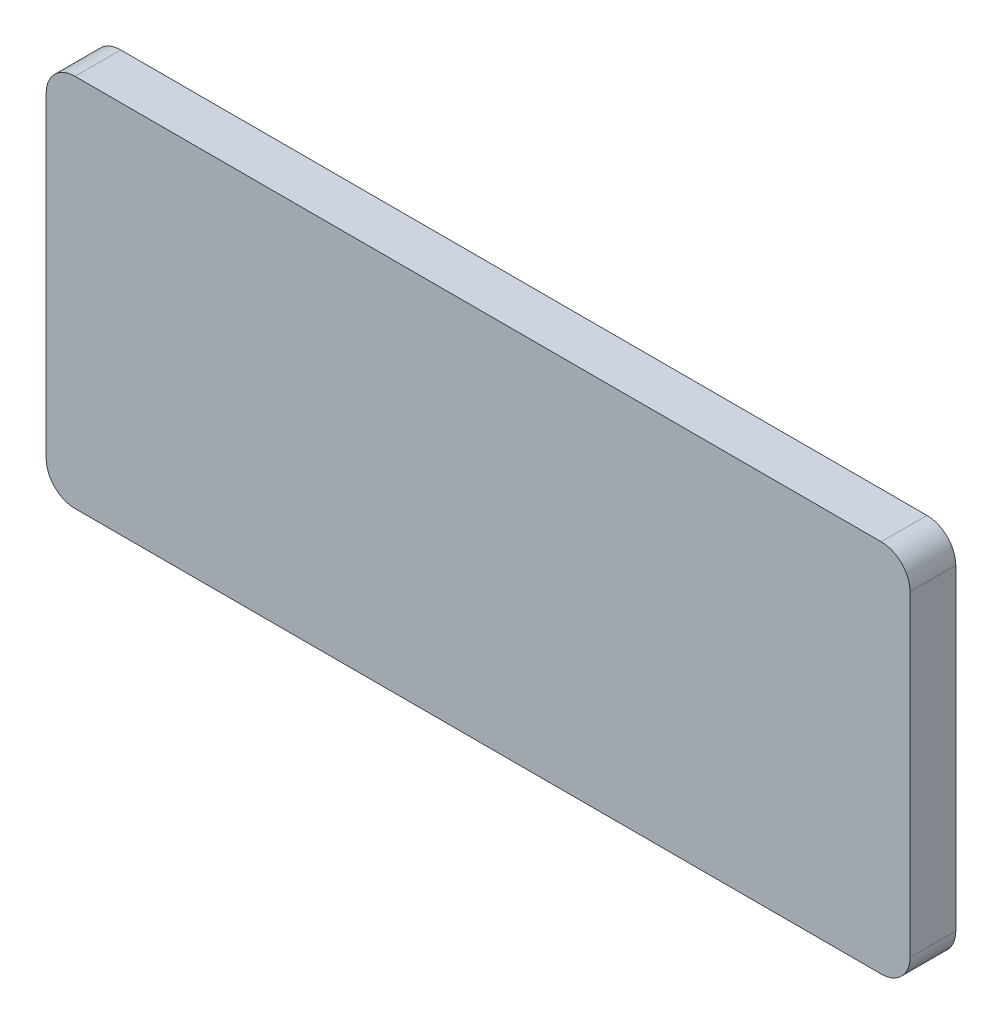
from build123d import *

# Parameters (mm, degrees)
SKETCH1_W           = 60
SKETCH1_H           = 26
BOSS_EXTRUDE1_DEPTH = 3.175
FILLET1_R           = 2


with BuildPart() as part:
    # Sketch1 → Boss-Extrude1 (new body)
    with BuildSketch(Plane.XY):
        with Locations((-30, 13)):
            Rectangle(SKETCH1_W, SKETCH1_H)
    extrude(amount=BOSS_EXTRUDE1_DEPTH)

    # Fillet1
    fillet1_edges = [part.edges().sort_by_distance(p)[0] for p in [
        (0, 0, 1.5875),
        (-60, 0, 1.5875),
        (-60, 26, 1.5875),
        (0, 26, 1.5875),
    ]]
    fillet(fillet1_edges, radius=FILLET1_R)


solid = part.part
